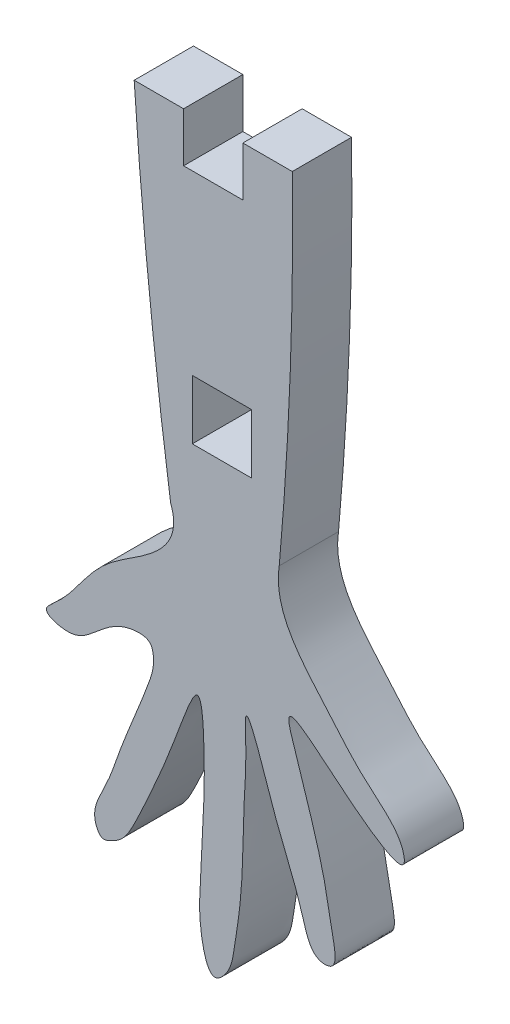
from build123d import *

# Parameters (mm, degrees)
SKETCH1_W           = 3
SKETCH1_H           = 3
BOSS_EXTRUDE1_DEPTH = 3


with BuildPart() as part:
    # Sketch1 → Boss-Extrude1 (new body)
    with BuildSketch(Plane.XY):
        with BuildLine():
            Line((0, 0), (2.5, 0))
            Line((2.5, 0), (2.5, -2.5))
            Line((2.5, -2.5), (5.5, -2.5))
            Line((5.5, -2.5), (5.5, 0))
            Line((5.5, 0), (8, 0))
            ThreePointArc((8, 0), (7.898472015, -8.813958175), (7.340873864, -17.610846883))
            Line((7.340873864, -17.610846883), (1.84428124, -17.610846883))
            ThreePointArc((1.84428124, -17.610846883), (0.754046794, -8.823026927), (0, 0))
        make_face()
        with Locations((4.440873864, -12.965345489)):
            Rectangle(SKETCH1_W, SKETCH1_H, mode=Mode.SUBTRACT)
        with BuildLine():
            Line((1.84428124, -17.610846883), (7.340873864, -17.610846883))
            add(Edge.make_bspline(
                [(1.84428124, -17.610846883), (2.367461616, -18.945064706), (0.89143249, -20.472923739), (-1.074588715, -21.539533623), (-2.607597499, -23.104781784), (-3.261165038, -24.308562294), (-4.797572704, -25.557714995), (-3.1231831, -26.06118696), (-1.855443028, -25.123769597), (-0.721206203, -23.996221845), (0.783008461, -24.098392688), (1.110654242, -25.016137737), (0.419413644, -26.992082641), (-0.59552629, -29.248135161), (-1.376669692, -31.683732496), (-2.290936918, -33.114557384), (-1.63944696, -34.131737339), (-1.12194627, -33.899004132), (-0.494849333, -33.541475945), (0.067647636, -32.489771911), (0.853189916, -30.798652355), (1.75538999, -28.707681828), (2.360557929, -27.016583299), (3.404981709, -24.358492532), (3.581250449, -28.121664114), (3.514427393, -30.253512547), (3.359625006, -33.320678545), (3.241118081, -35.306035152), (3.820781564, -37.77751066), (4.891280808, -36.610778367), (5.103013956, -35.242650891), (5.407502083, -33.355095359), (5.506075907, -31.182368072), (5.538727583, -28.720789157), (5.707443802, -27.00045349), (5.530572274, -23.87512955), (6.77497625, -27.69140696), (7.538915522, -29.789996543), (8.398693465, -31.694157075), (8.940264291, -33.967828385), (10.372981208, -33.897672352), (9.933897367, -32.086970025), (9.731596119, -30.627010484), (9.283436558, -28.880802899), (8.737002039, -27.150709863), (8.298606352, -25.751569716), (7.28594942, -22.841729244), (10.438861461, -25.958489723), (13.882957195, -28.254254459), (13.547816915, -26.670551772), (12.869277794, -25.775388668), (11.317812326, -24.582720798), (9.159966375, -21.920973312), (7.021760435, -19.727377218), (7.340873864, -17.610846883)],
                knots=[0, 0, 0, 0, 0.034557404, 0.057170592, 0.068150729, 0.098636953, 0.104139208, 0.115965177, 0.128946734, 0.153767299, 0.162728252, 0.164167147, 0.182206392, 0.220910801, 0.240003753, 0.260619007, 0.265391123, 0.269659432, 0.275164048, 0.287715353, 0.30328738, 0.332625277, 0.351966861, 0.366761286, 0.389690915, 0.414734793, 0.449813724, 0.470499029, 0.487839114, 0.495725811, 0.507068991, 0.531104134, 0.551931172, 0.573033244, 0.602577929, 0.612823326, 0.644235201, 0.658343354, 0.691154788, 0.709441588, 0.713370519, 0.728485416, 0.74657055, 0.765207104, 0.78064888, 0.80027966, 0.81402266, 0.851718479, 0.88087957, 0.883952598, 0.896409812, 0.914328492, 0.942057881, 1, 1, 1, 1], degree=3))
        make_face()
    extrude(amount=BOSS_EXTRUDE1_DEPTH)


solid = part.part
